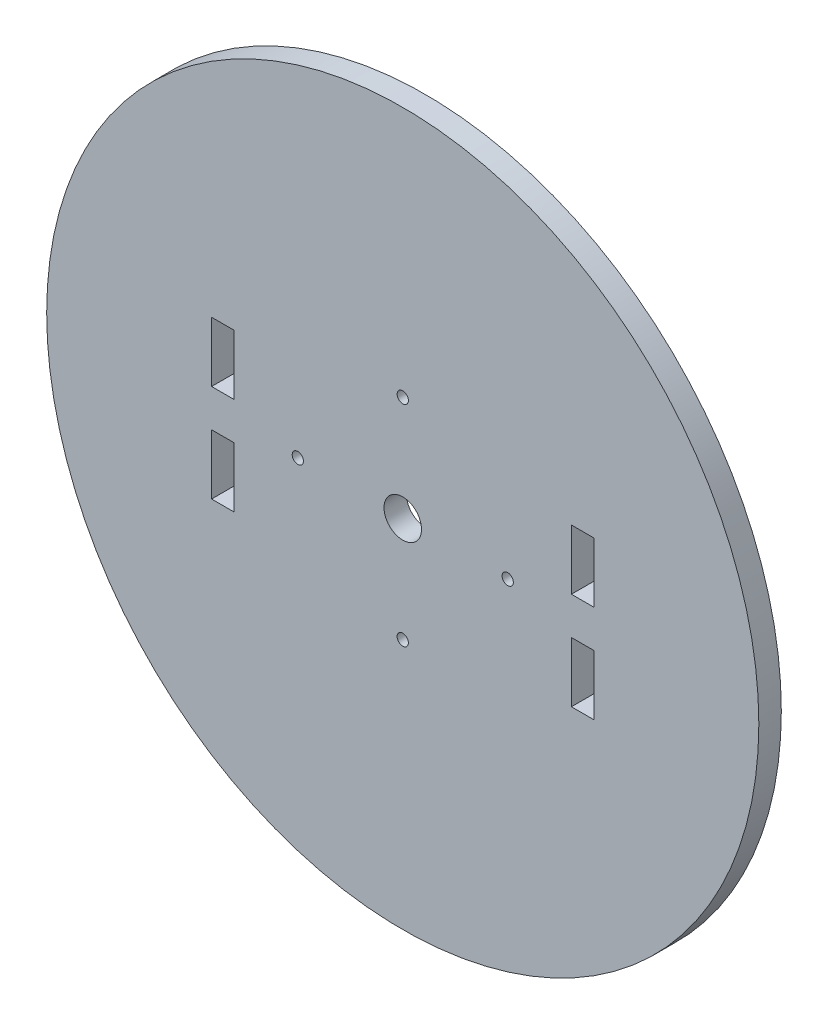
from build123d import *

# Parameters (mm, degrees)
CROQUIS1_R              = 47.5
CROQUIS1_R_2            = 2.5
CROQUIS1_R_3            = 0.75
SALIENTE_EXTRUIR1_DEPTH = 3
CROQUIS2_W              = 3
CROQUIS2_H              = 8
CORTAR_EXTRUIR1_DEPTH   = 4


with BuildPart() as part:
    # Croquis1 → Saliente-Extruir1 (new body)
    with BuildSketch(Plane.XY):
        Circle(CROQUIS1_R)
        Circle(CROQUIS1_R_2, mode=Mode.SUBTRACT)
        with Locations((0, -14)):
            Circle(CROQUIS1_R_3, mode=Mode.SUBTRACT)
        with Locations((-14, 0)):
            Circle(CROQUIS1_R_3, mode=Mode.SUBTRACT)
        with Locations((0, 14)):
            Circle(CROQUIS1_R_3, mode=Mode.SUBTRACT)
        with Locations((14, 0)):
            Circle(CROQUIS1_R_3, mode=Mode.SUBTRACT)
    extrude(amount=SALIENTE_EXTRUIR1_DEPTH)

    # Croquis2 → Cortar-Extruir1 (cut, through all)
    with BuildSketch(Plane.XY.offset(3)):
        with Locations((24, 6.5)):
            Rectangle(CROQUIS2_W, CROQUIS2_H)
        with Locations((24, -6.5)):
            Rectangle(CROQUIS2_W, CROQUIS2_H)
        with Locations((-24, -6.5)):
            Rectangle(CROQUIS2_W, CROQUIS2_H)
        with Locations((-24, 6.5)):
            Rectangle(CROQUIS2_W, CROQUIS2_H)
    extrude(amount=-CORTAR_EXTRUIR1_DEPTH, mode=Mode.SUBTRACT)


solid = part.part
